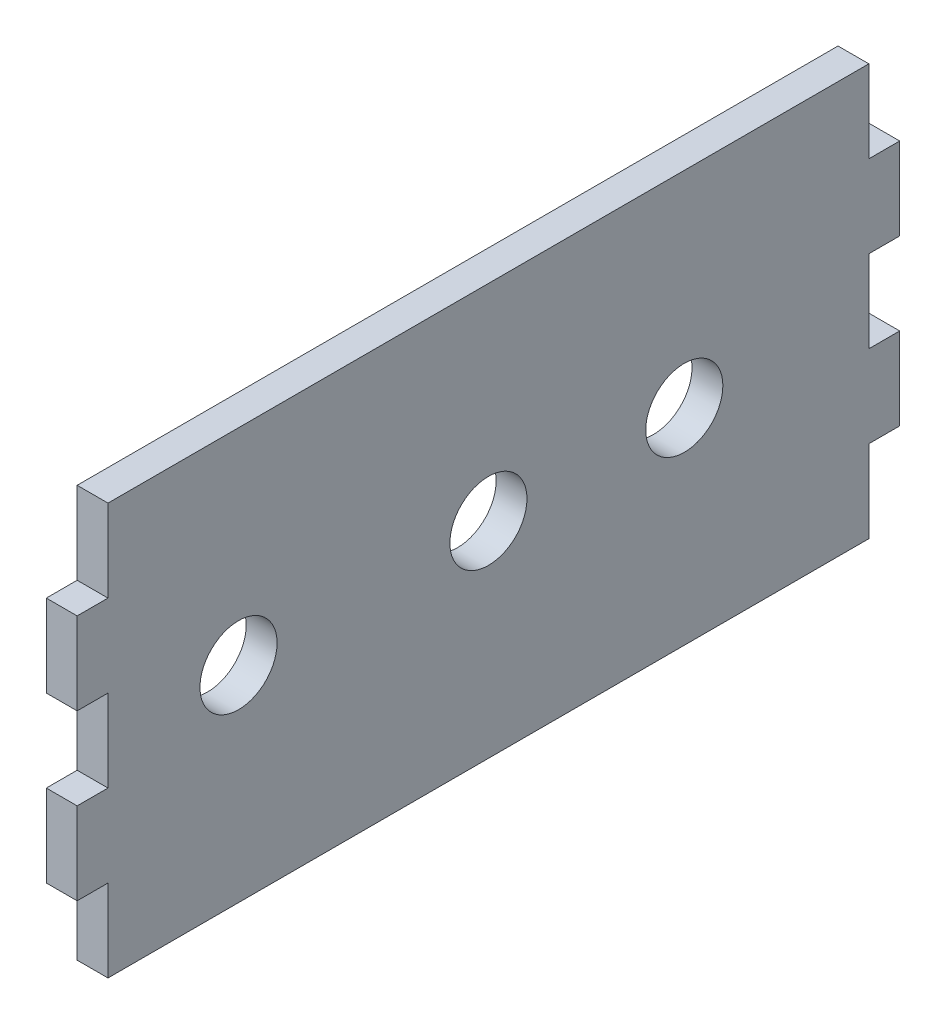
from build123d import *

# Parameters (mm, degrees)
CROQUIS1_W              = 160
CROQUIS1_H              = 80
SALIENTE_EXTRUIR1_DEPTH = 6
CROQUIS2_R              = 7.5
CORTAR_EXTRUIR1_DEPTH   = 6
CROQUIS3_W              = 6
CROQUIS3_H              = 16
CORTAR_EXTRUIR2_DEPTH   = 6


with BuildPart() as part:
    # Croquis1 → Saliente-Extruir1 (new body)
    with BuildSketch(Plane(origin=(0, 0, 0), x_dir=(0, 0, -1), z_dir=(1, 0, 0))):
        Rectangle(CROQUIS1_W, CROQUIS1_H)
    extrude(amount=SALIENTE_EXTRUIR1_DEPTH)

    # Croquis2 → Cortar-Extruir1 (cut)
    with BuildSketch(Plane(origin=(6, 0, 0), x_dir=(0, 0, -1), z_dir=(1, 0, 0))):
        with Locations((-48.61, 0)):
            Circle(CROQUIS2_R)
        Circle(CROQUIS2_R)
        with Locations((38.1, 0)):
            Circle(CROQUIS2_R)
    extrude(amount=-CORTAR_EXTRUIR1_DEPTH, mode=Mode.SUBTRACT)

    # Croquis3 → Cortar-Extruir2 (cut)
    with BuildSketch(Plane(origin=(6, 0, 0), x_dir=(0, 0, -1), z_dir=(1, 0, 0))):
        with Locations((-77, 32)):
            Rectangle(CROQUIS3_W, CROQUIS3_H)
        with Locations((-77, -32)):
            Rectangle(CROQUIS3_W, CROQUIS3_H)
        with Locations((77, -32)):
            Rectangle(CROQUIS3_W, CROQUIS3_H)
        with Locations((77, 32)):
            Rectangle(CROQUIS3_W, CROQUIS3_H)
        with Locations((77, 0)):
            Rectangle(CROQUIS3_W, CROQUIS3_H)
        with Locations((-77, 0)):
            Rectangle(CROQUIS3_W, CROQUIS3_H)
    extrude(amount=-CORTAR_EXTRUIR2_DEPTH, mode=Mode.SUBTRACT)


solid = part.part
